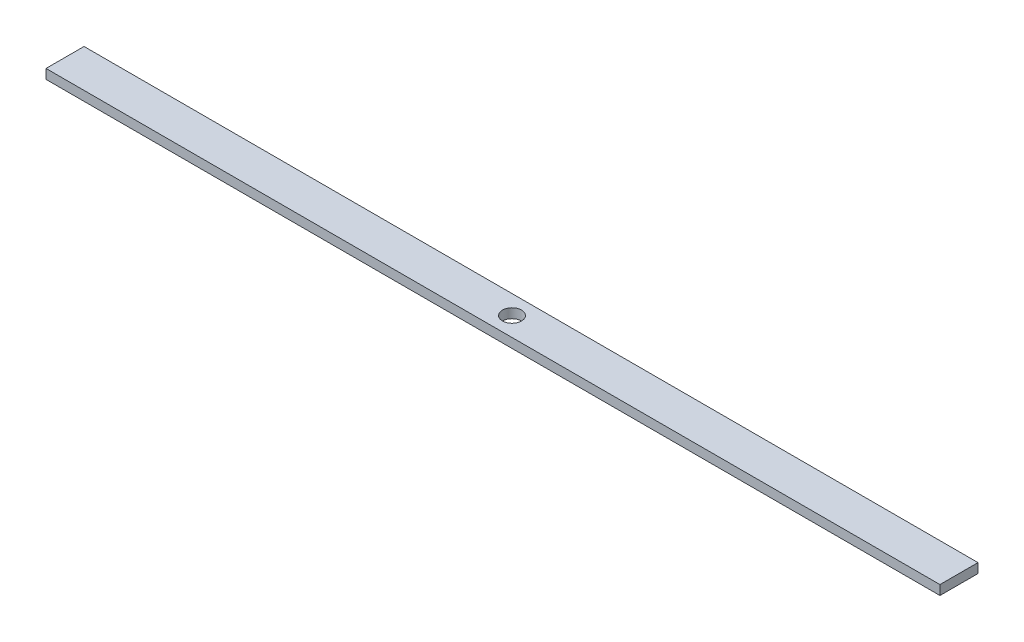
from build123d import *

# Parameters (mm, degrees)
SKETCH1_W           = 596.9
SKETCH1_H           = 25.4
SKETCH1_R           = 6.35
BOSS_EXTRUDE1_DEPTH = 6.35


with BuildPart() as part:
    # Sketch1 → Boss-Extrude1 (new body)
    with BuildSketch(Plane(origin=(0, 0, 0), x_dir=(1, 0, 0), z_dir=(0, 1, 0))):
        Rectangle(SKETCH1_W, SKETCH1_H)
        Circle(SKETCH1_R, mode=Mode.SUBTRACT)
    extrude(amount=BOSS_EXTRUDE1_DEPTH)


solid = part.part
